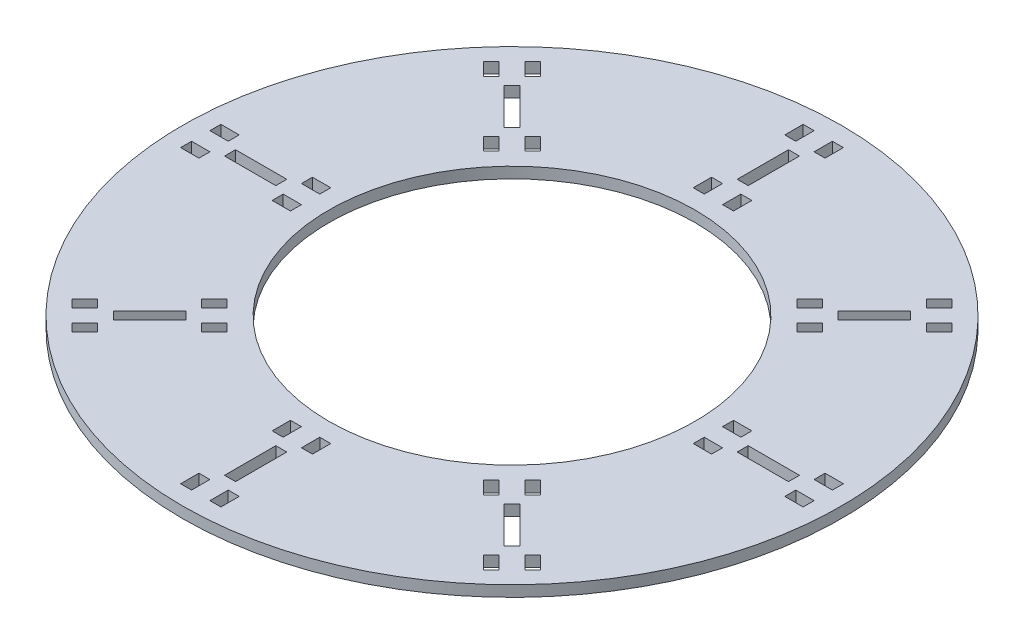
from build123d import *

# Parameters (mm, degrees)
SKETCH1_R           = 90
BOSS_EXTRUDE1_DEPTH = 3
SKETCH2_W           = 3
SKETCH2_H           = 14
CUT_EXTRUDE2_DEPTH  = 3
CIRPATTERN1_COUNT   = 8
SKETCH16_W          = 3
SKETCH16_H          = 5
CUT_EXTRUDE5_DEPTH  = 3
CIRPATTERN2_COUNT   = 8
SKETCH24_R          = 50
CUT_EXTRUDE6_DEPTH  = 3


with BuildPart() as part:
    # Sketch1 → Boss-Extrude1 (new body)
    with BuildSketch(Plane(origin=(0, 0, 0), x_dir=(1, 0, 0), z_dir=(0, 1, 0))):
        Circle(SKETCH1_R)
    extrude(amount=BOSS_EXTRUDE1_DEPTH)

    # Sketch2 → Cut-Extrude2 (cut)
    with BuildSketch(Plane(origin=(0, 3, 0), x_dir=(1, 0, 0), z_dir=(0, 1, 0))):
        with Locations((0, 70)):
            Rectangle(SKETCH2_W, SKETCH2_H)
    cut_extrude2 = extrude(amount=-CUT_EXTRUDE2_DEPTH, mode=Mode.SUBTRACT)

    # CirPattern1: Cut-Extrude2 ×8 about axis
    cirpattern1_axis = Axis((0, 0, 0), (0, 1, 0))
    for i in range(1, CIRPATTERN1_COUNT):
        add(cut_extrude2.rotate(cirpattern1_axis, i * 360 / CIRPATTERN1_COUNT), mode=Mode.SUBTRACT)

    # Sketch16 → Cut-Extrude5 (cut)
    with BuildSketch(Plane(origin=(0, 3, 0), x_dir=(1, 0, 0), z_dir=(0, 1, 0))):
        with Locations((-4, 82.5)):
            Rectangle(SKETCH16_W, SKETCH16_H)
        with Locations((4, 82.5)):
            Rectangle(SKETCH16_W, SKETCH16_H)
        with Locations((-4, 57.5)):
            Rectangle(SKETCH16_W, SKETCH16_H)
        with Locations((4, 57.5)):
            Rectangle(SKETCH16_W, SKETCH16_H)
    cut_extrude5 = extrude(amount=-CUT_EXTRUDE5_DEPTH, mode=Mode.SUBTRACT)

    # CirPattern2: Cut-Extrude5 ×8 about axis
    cirpattern2_axis = Axis((0, 0, 0), (0, 1, 0))
    for i in range(1, CIRPATTERN2_COUNT):
        add(cut_extrude5.rotate(cirpattern2_axis, i * 360 / CIRPATTERN2_COUNT), mode=Mode.SUBTRACT)

    # Sketch24 → Cut-Extrude6 (cut)
    with BuildSketch(Plane(origin=(0, 3, 0), x_dir=(1, 0, 0), z_dir=(0, 1, 0))):
        Circle(SKETCH24_R)
    extrude(amount=-CUT_EXTRUDE6_DEPTH, mode=Mode.SUBTRACT)


solid = part.part
